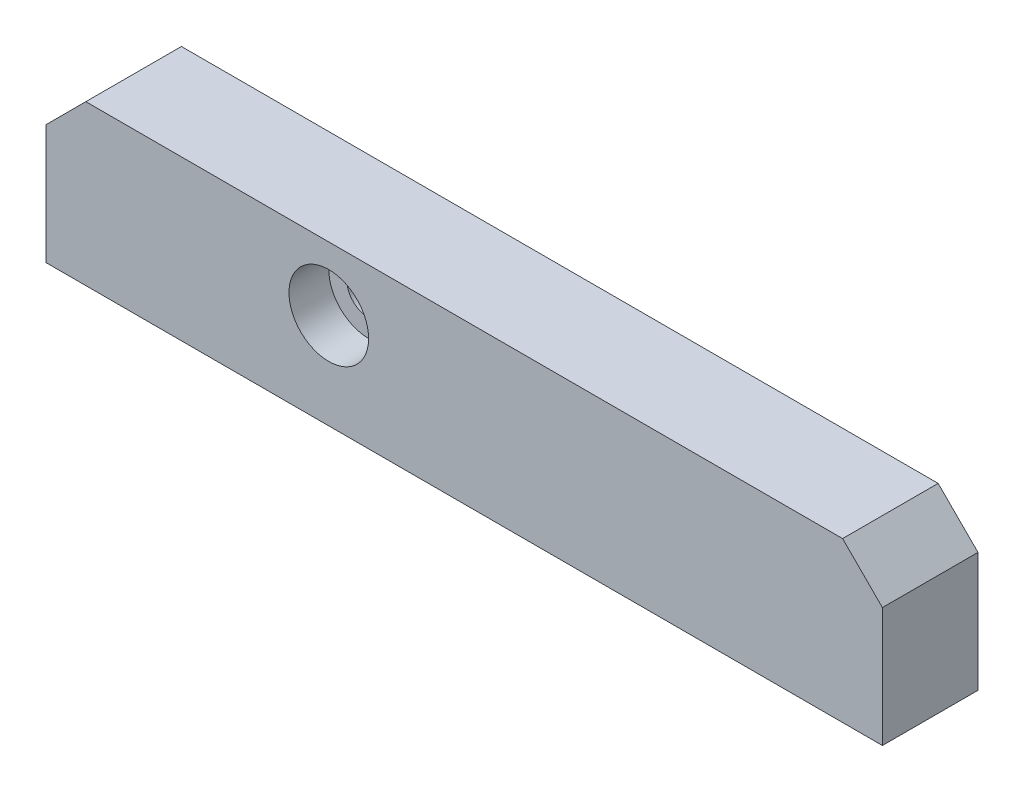
from build123d import *

# Parameters (mm, degrees)
BOSS_EXTRUDE1_DEPTH                             = 12
CBORE_FOR_M5_SOCKET_HEAD_CAP_SCREW1_D           = 5.5
CBORE_FOR_M5_SOCKET_HEAD_CAP_SCREW1_CBORE_D     = 10
CBORE_FOR_M5_SOCKET_HEAD_CAP_SCREW1_CBORE_DEPTH = 5
M5X0_8_TAPPED_HOLE1_D                           = 4.2
M5X0_8_TAPPED_HOLE1_DEPTH                       = 14
M5X0_8_TAPPED_HOLE1_TIP                         = 1.2618073


with BuildPart() as part:
    # Sketch1 → Boss-Extrude1 (new body)
    with BuildSketch(Plane.XY):
        Polygon((-47.5, 20), (-52.5, 15), (-52.5, 0), (52.5, 0), (52.5, 15), (47.5, 20), align=None)
    extrude(amount=BOSS_EXTRUDE1_DEPTH)

    # CBORE for M5 Socket Head Cap Screw1 (through all)
    with Locations(Plane.XY.offset(12)):
        with Locations((-17, 12)):
            CounterBoreHole(CBORE_FOR_M5_SOCKET_HEAD_CAP_SCREW1_D / 2, CBORE_FOR_M5_SOCKET_HEAD_CAP_SCREW1_CBORE_D / 2, CBORE_FOR_M5_SOCKET_HEAD_CAP_SCREW1_CBORE_DEPTH)

    # M5x0.8 Tapped Hole1
    with Locations(Plane.XZ):
        with Locations((-37.5, 6), (37.5, 6)):
            Hole(M5X0_8_TAPPED_HOLE1_D / 2, depth=M5X0_8_TAPPED_HOLE1_DEPTH)
            with Locations((0, 0, -(M5X0_8_TAPPED_HOLE1_DEPTH + M5X0_8_TAPPED_HOLE1_TIP / 2))):  # 118° drill point
                Cone(0, M5X0_8_TAPPED_HOLE1_D / 2, M5X0_8_TAPPED_HOLE1_TIP, mode=Mode.SUBTRACT)


solid = part.part
